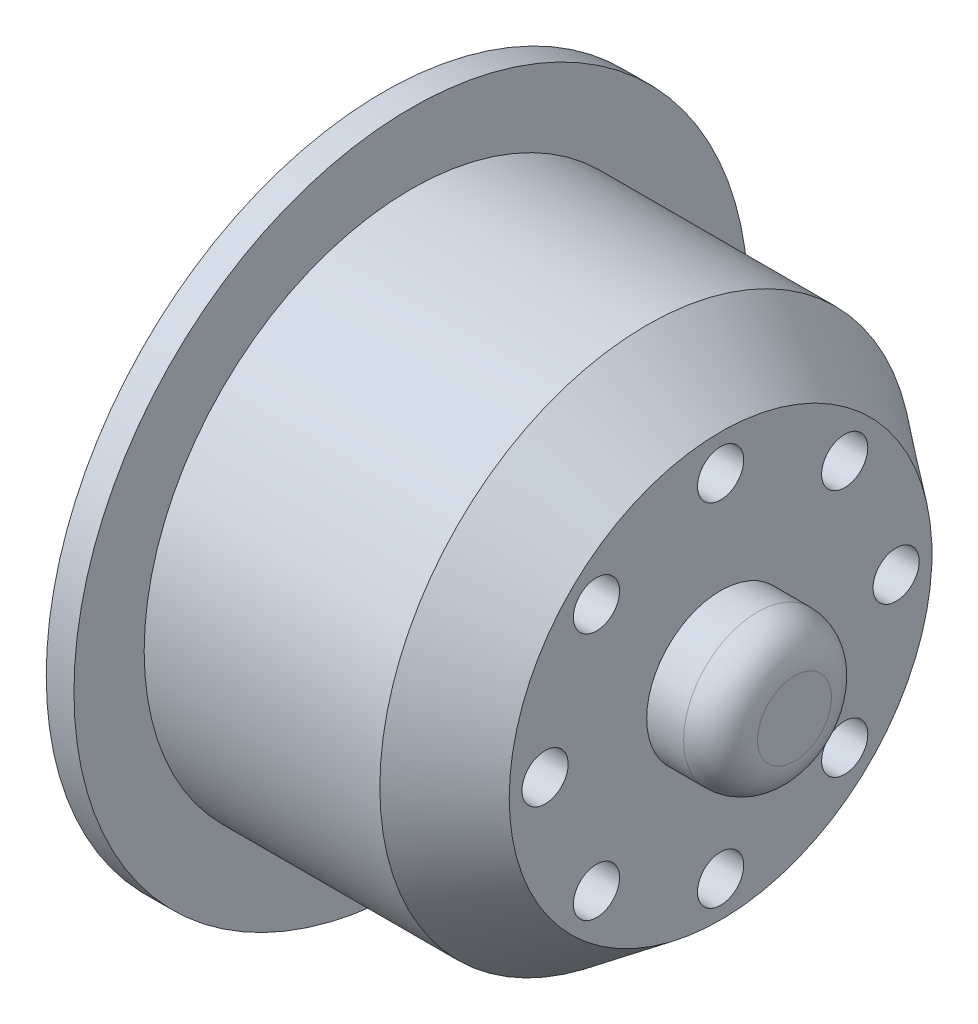
from build123d import *

# Parameters (mm, degrees)
SKETCH2_R          = 1.25
CUT_EXTRUDE1_DEPTH = 19.25
FILLET1_R          = 2
SKETCH3_R          = 2.5
CUT_EXTRUDE2_DEPTH = 13.25
SKETCH4_R          = 5.1
CUT_EXTRUDE3_DEPTH = 6


with BuildPart() as part:
    # Sketch1 → Revolve1 (revolve)
    with BuildSketch(Plane(origin=(0, 0, 0), x_dir=(1, 0, 0), z_dir=(0, 1, 0))):
        Polygon((-6.130434783, 14.45), (6.626387667, 14.45), (10.619565217, 11.440924884), (10.619565217, 4), (14.619565217, 4), (14.619565217, 0), (13.372742768, 0), (-6.130434783, 0), (-7.630434783, 0), (-7.630434783, 18.25), (-6.130434783, 18.25), align=None)
    revolve(axis=Axis((-12.391304348, 0, 0), (1, 0, 0)))

    # Sketch2 → Cut-Extrude1 (cut, through all)
    with BuildSketch(Plane(origin=(10.619565217, 0, 0), x_dir=(0, 0, -1), z_dir=(1, 0, 0))):
        with Locations((0, 9.5)):
            Circle(SKETCH2_R)
        with Locations((6.717514421, 6.717514421)):
            Circle(SKETCH2_R)
        with Locations((9.5, 0)):
            Circle(SKETCH2_R)
        with Locations((6.717514421, -6.717514421)):
            Circle(SKETCH2_R)
        with Locations((0, -9.5)):
            Circle(SKETCH2_R)
        with Locations((-6.717514421, -6.717514421)):
            Circle(SKETCH2_R)
        with Locations((-9.5, 0)):
            Circle(SKETCH2_R)
        with Locations((-6.717514421, 6.717514421)):
            Circle(SKETCH2_R)
    extrude(amount=-CUT_EXTRUDE1_DEPTH, mode=Mode.SUBTRACT)

    # Fillet1
    fillet1_edges = [part.edges().sort_by_distance(p)[0] for p in [
        (14.619565217, 0, 4),
    ]]
    fillet(fillet1_edges, radius=FILLET1_R)

    # Sketch3 → Cut-Extrude2 (cut)
    with BuildSketch(Plane.ZY.offset(7.630434783)):
        with Locations((0, 9.5)):
            Circle(SKETCH3_R)
        with Locations((6.717514421, 6.717514421)):
            Circle(SKETCH3_R)
        with Locations((9.5, 0)):
            Circle(SKETCH3_R)
        with Locations((6.717514421, -6.717514421)):
            Circle(SKETCH3_R)
        with Locations((0, -9.5)):
            Circle(SKETCH3_R)
        with Locations((-6.717514421, -6.717514421)):
            Circle(SKETCH3_R)
        with Locations((-9.5, 0)):
            Circle(SKETCH3_R)
        with Locations((-6.717514421, 6.717514421)):
            Circle(SKETCH3_R)
    extrude(amount=-CUT_EXTRUDE2_DEPTH, mode=Mode.SUBTRACT)

    # Sketch4 → Cut-Extrude3 (cut)
    with BuildSketch(Plane.ZY.offset(7.630434783)):
        Circle(SKETCH4_R)
    extrude(amount=-CUT_EXTRUDE3_DEPTH, mode=Mode.SUBTRACT)


solid = part.part
